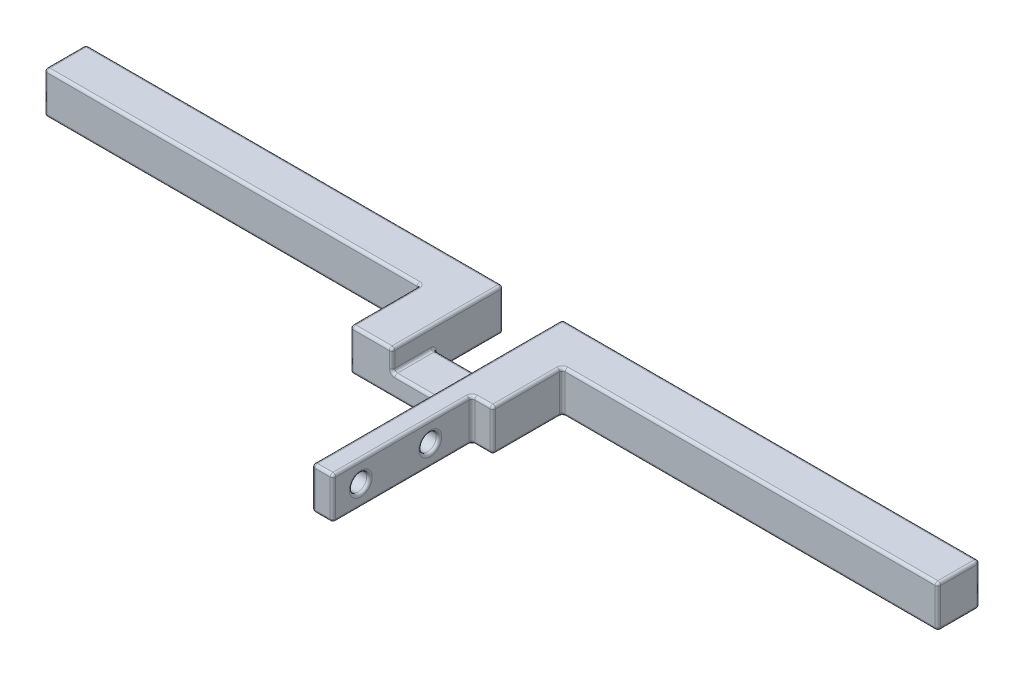
from build123d import *

# Parameters (mm, degrees)
EXTRUDE_1_DEPTH     = 6
SKETCH_2_W          = 8.5
SKETCH_2_H          = 6
CUT_EXTRUDE_1_DEPTH = 3
SKETCH_3_R          = 1.25
CUT_EXTRUDE_2_DEPTH = 72.5
FILLET_1_R          = 0.4


with BuildPart() as part:
    # 草图1 → 凸台-拉伸1 (new body)
    with BuildSketch(Plane(origin=(0, 0, 0), x_dir=(1, 0, 0), z_dir=(0, 1, 0))):
        Polygon((4.25, 0), (-4.25, 0), (-4.25, 10), (-64.25, 10), (-64.25, 4), (-10.25, 4), (-10.25, -6), (4.25, -6), (4.25, -26), (7.25, -26), (7.25, -6), (10.25, -6), (10.25, 4), (64.25, 4), (64.25, 10), (4.25, 10), align=None)
    extrude(amount=EXTRUDE_1_DEPTH)

    # 草图2 → 切除-拉伸1 (cut)
    with BuildSketch(Plane(origin=(0, 6, 0), x_dir=(1, 0, 0), z_dir=(0, 1, 0))):
        with Locations((0, -3)):
            Rectangle(SKETCH_2_W, SKETCH_2_H)
    extrude(amount=-CUT_EXTRUDE_1_DEPTH, mode=Mode.SUBTRACT)

    # 草图3 → 切除-拉伸2 (cut, through all)
    with BuildSketch(Plane(origin=(7.25, 0, 0), x_dir=(0, 0, -1), z_dir=(1, 0, 0))):
        with Locations((-12, 3)):
            Circle(SKETCH_3_R)
        with Locations((-22, 3)):
            Circle(SKETCH_3_R)
    extrude(amount=-CUT_EXTRUDE_2_DEPTH, mode=Mode.SUBTRACT)

    # 圆角1
    fillet_1_edges = [part.edges().sort_by_distance(p)[0] for p in [
        (5.75, 6, 26),
        (10.25, 0, 1),
        (37.25, 0, -4),
        (64.25, 0, -7),
        (4.25, 6, 8),
        (34.25, 0, -10),
        (4.25, 0, -5),
        (0, 0, 0),
        (-4.25, 0, -5),
        (-34.25, 0, -10),
        (-64.25, 0, -7),
        (-37.25, 0, -4),
        (-10.25, 0, 1),
        (-3, 0, 6),
        (4.25, 0, 16),
        (-7.25, 6, 6),
        (5.75, 0, 26),
        (7.25, 0, 16),
        (8.75, 0, 6),
        (-10.25, 6, 1),
        (10.25, 3, 6),
        (10.25, 3, -4),
        (64.25, 3, -4),
        (64.25, 3, -10),
        (4.25, 3, -10),
        (-4.25, 3, -10),
        (-64.25, 3, -10),
        (-64.25, 3, -4),
        (-10.25, 3, -4),
        (-10.25, 3, 6),
        (4.25, 3, 26),
        (7.25, 3, 26),
        (7.25, 3, 6),
        (-37.25, 6, -4),
        (-64.25, 6, -7),
        (-34.25, 6, -10),
        (-4.25, 6, -2),
        (4.25, 1.5, 6),
        (8.75, 6, 6),
        (-4.25, 1.5, 0),
        (4.25, 1.5, 0),
        (4.25, 3, 3),
        (0, 3, 6),
        (34.25, 6, -10),
        (-4.25, 3, 3),
        (-4.25, 4.5, 6),
        (0, 3, 0),
        (64.25, 6, -7),
        (37.25, 6, -4),
        (10.25, 6, 1),
        (4.25, 3, 13.25),
        (7.25, 3, 13.25),
        (4.25, 3, 23.25),
        (7.25, 3, 23.25),
        (7.25, 6, 16),
    ]]
    fillet(fillet_1_edges, radius=FILLET_1_R)


solid = part.part
